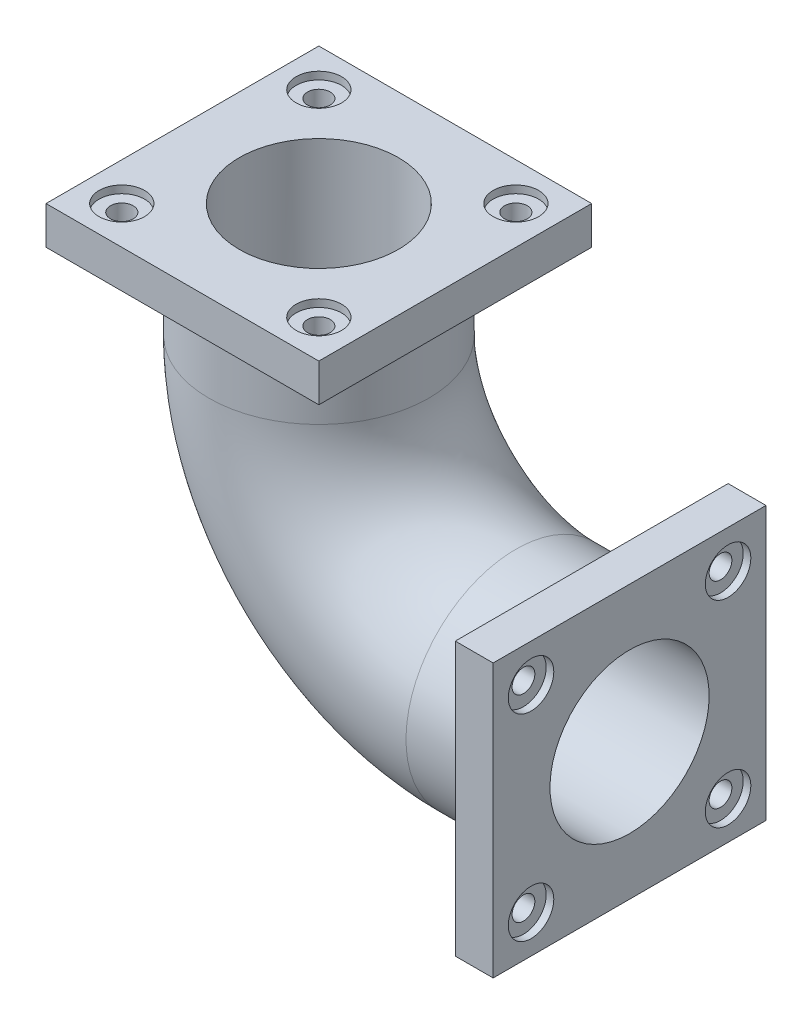
from build123d import *

# Parameters (mm, degrees)
IZIM4_R                     = 145
IZIM5_W                     = 360
IZIM5_H                     = 360
Y_KSEKLIK_EKSTR_ZYON1_DEPTH = 50
IZIM6_W                     = 360
IZIM6_H                     = 360
Y_KSEKLIK_EKSTR_ZYON2_DEPTH = 50
IZIM7_R                     = 15
KES_EKSTR_ZYON1_DEPTH       = 50
IZIM8_R                     = 30
KES_EKSTR_ZYON2_DEPTH       = 10
IZIM9_R                     = 15
Y_KSEKLIK_EKSTR_ZYON3_DEPTH = 50
IZIM9_2_R                   = 15
KES_EKSTR_ZYON3_DEPTH       = 50
IZIM10_R                    = 30
KES_EKSTR_ZYON4_DEPTH       = 10
KES_S_P_R2_PROFILE_R        = 105
KES_EKSTR_ZYON5_START       = -50
IZIM47_R                    = 105
KES_EKSTR_ZYON5_DEPTH       = 50
IZIM48_R                    = 105
KES_EKSTR_ZYON6_DEPTH       = 50


with BuildPart() as part:
    # Süpür1: sweep along a path in Çizim1
    with BuildLine(Plane.XY) as s_p_r1_path:
        Line((0, 0), (-150, 0))
        ThreePointArc((-150, 0), (-333.847763109, 76.152236891), (-410, 260))
        Line((-410, 260), (-410, 410))
    # Çizim4 → Süpür1 (sweep)
    with BuildSketch(Plane(origin=(0, 0, 0), x_dir=(0, 0, -1), z_dir=(1, 0, 0))):
        Circle(IZIM4_R)
    sweep(path=s_p_r1_path.line)

    # Çizim5 → Yükseklik-Ekstrüzyon1 (add)
    with BuildSketch(Plane(origin=(0, 410, 0), x_dir=(1, 0, 0), z_dir=(0, 1, 0))):
        with Locations((-410, 0)):
            Rectangle(IZIM5_W, IZIM5_H)
    extrude(amount=-Y_KSEKLIK_EKSTR_ZYON1_DEPTH)

    # Çizim6 → Yükseklik-Ekstrüzyon2 (add)
    with BuildSketch(Plane(origin=(0, 0, 0), x_dir=(0, 0, -1), z_dir=(1, 0, 0))):
        Rectangle(IZIM6_W, IZIM6_H)
    extrude(amount=-Y_KSEKLIK_EKSTR_ZYON2_DEPTH)

    # Çizim7 → Kes-Ekstrüzyon1 (cut)
    with BuildSketch(Plane(origin=(0, 410, 0), x_dir=(1, 0, 0), z_dir=(0, 1, 0))):
        with Locations((-540, 130)):
            Circle(IZIM7_R)
        with Locations((-280, 130)):
            Circle(IZIM7_R)
        with Locations((-540, -130)):
            Circle(IZIM7_R)
        with Locations((-280, -130)):
            Circle(IZIM7_R)
    extrude(amount=-KES_EKSTR_ZYON1_DEPTH, mode=Mode.SUBTRACT)

    # Çizim8 → Kes-Ekstrüzyon2 (cut)
    with BuildSketch(Plane(origin=(0, 410, 0), x_dir=(1, 0, 0), z_dir=(0, 1, 0))):
        with Locations((-540, 130)):
            Circle(IZIM8_R)
        with Locations((-280, 130)):
            Circle(IZIM8_R)
        with Locations((-280, -130)):
            Circle(IZIM8_R)
        with Locations((-540, -130)):
            Circle(IZIM8_R)
    extrude(amount=-KES_EKSTR_ZYON2_DEPTH, mode=Mode.SUBTRACT)

    # Çizim9 → Yükseklik-Ekstrüzyon3 (add)
    with BuildSketch(Plane(origin=(0, 0, 0), x_dir=(0, 0, -1), z_dir=(1, 0, 0))):
        with Locations((-130, 130)):
            Circle(IZIM9_R)
        with Locations((130, 130)):
            Circle(IZIM9_R)
        with Locations((130, -130)):
            Circle(IZIM9_R)
        with Locations((-130, -130)):
            Circle(IZIM9_R)
    extrude(amount=-Y_KSEKLIK_EKSTR_ZYON3_DEPTH)

    # Çizim9<2> → Kes-Ekstrüzyon3 (cut)
    with BuildSketch(Plane(origin=(0, 0, 0), x_dir=(0, 0, -1), z_dir=(1, 0, 0))):
        with Locations((-130, 130)):
            Circle(IZIM9_2_R)
        with Locations((130, 130)):
            Circle(IZIM9_2_R)
        with Locations((130, -130)):
            Circle(IZIM9_2_R)
        with Locations((-130, -130)):
            Circle(IZIM9_2_R)
    extrude(amount=-KES_EKSTR_ZYON3_DEPTH, mode=Mode.SUBTRACT)

    # Çizim10 → Kes-Ekstrüzyon4 (cut)
    with BuildSketch(Plane(origin=(0, 0, 0), x_dir=(0, 0, -1), z_dir=(1, 0, 0))):
        with Locations((-130, 130)):
            Circle(IZIM10_R)
        with Locations((130, 130)):
            Circle(IZIM10_R)
        with Locations((130, -130)):
            Circle(IZIM10_R)
        with Locations((-130, -130)):
            Circle(IZIM10_R)
    extrude(amount=-KES_EKSTR_ZYON4_DEPTH, mode=Mode.SUBTRACT)

    # Kes-Süpür2: sweep along a path in Çizim11
    with BuildLine(Plane.XY) as kes_s_p_r2_path:
        Line((-50, 0), (-150, 0))
        ThreePointArc((-150, 0), (-333.847763109, 76.152236891), (-410, 260))
        Line((-410, 260), (-410, 360))
    # Kes-Süpür2 profile (on start of the path) → Kes-Süpür2 (sweep, cut)
    with BuildSketch(Plane(origin=(-50, 0, 0), x_dir=(0, -1, 0), z_dir=(-1, 0, 0))):
        Circle(KES_S_P_R2_PROFILE_R)
    sweep(path=kes_s_p_r2_path.line, mode=Mode.SUBTRACT)

    # Çizim47 → Kes-Ekstrüzyon5 (cut)
    with BuildSketch(Plane(origin=(0, 0, 0), x_dir=(0, 0, -1), z_dir=(1, 0, 0)).offset(KES_EKSTR_ZYON5_START)):
        Circle(IZIM47_R)
    extrude(amount=KES_EKSTR_ZYON5_DEPTH, mode=Mode.SUBTRACT)

    # Çizim48 → Kes-Ekstrüzyon6 (cut)
    with BuildSketch(Plane(origin=(0, 410, 0), x_dir=(1, 0, 0), z_dir=(0, 1, 0))):
        with Locations((-410, 0)):
            Circle(IZIM48_R)
    extrude(amount=-KES_EKSTR_ZYON6_DEPTH, mode=Mode.SUBTRACT)


solid = part.part
